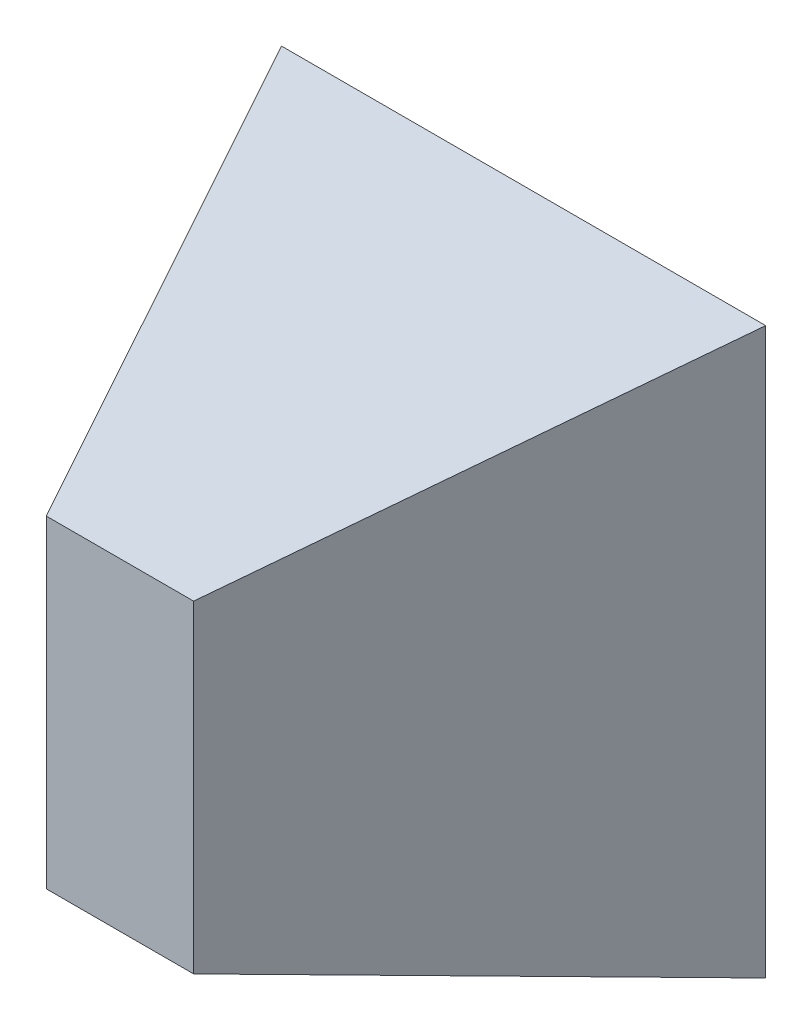
from build123d import *

# Parameters (mm, degrees)
SKETCH2_W = 92.71
SKETCH2_H = 203.2
SKETCH1_W = 304.8
SKETCH1_H = 355.6


with BuildPart() as part:
    # Sketch2 → Loft1 section 0
    with BuildSketch(Plane.XY.offset(254)):
        Rectangle(SKETCH2_W, SKETCH2_H)
    # Sketch1 → Loft1 section 1
    with BuildSketch(Plane.XY):
        Rectangle(SKETCH1_W, SKETCH1_H)
    loft()


solid = part.part
